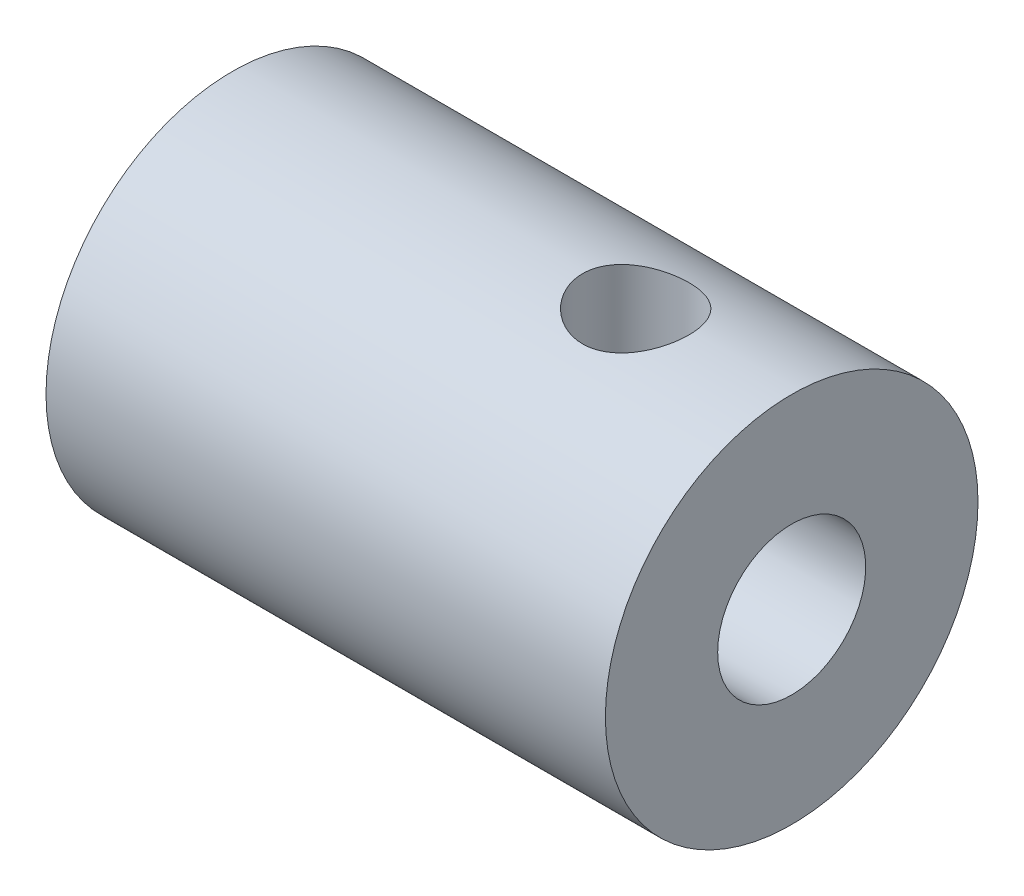
from build123d import *

# Parameters (mm, degrees)
SKETCH4_R               = 1.3589
CUT_EXTRUDE1_DEPTH      = 5.7625
CUT_EXTRUDE1_DEPTH_BACK = 5.7625


with BuildPart() as part:
    # Sketch3 → Revolve1 (revolve)
    with BuildSketch(Plane.XY):
        Polygon((-6.35, 4.7625), (-6.35, 3.175), (0, 3.175), (0, 1.8923), (7.9502, 1.8923), (7.9502, 4.7625), align=None)
    revolve(axis=Axis((0, 0, 0), (1, 0, 0)))

    # Sketch4 → Cut-Extrude1 (cut, two sides)
    with BuildSketch(Plane(origin=(0, 0, 0), x_dir=(1, 0, 0), z_dir=(0, 1, 0))) as cut_extrude1_sk:
        with Locations((3.9624, 0)):
            Circle(SKETCH4_R)
    extrude(amount=CUT_EXTRUDE1_DEPTH, mode=Mode.SUBTRACT)
    extrude(cut_extrude1_sk.sketch, amount=-CUT_EXTRUDE1_DEPTH_BACK, mode=Mode.SUBTRACT)


solid = part.part
